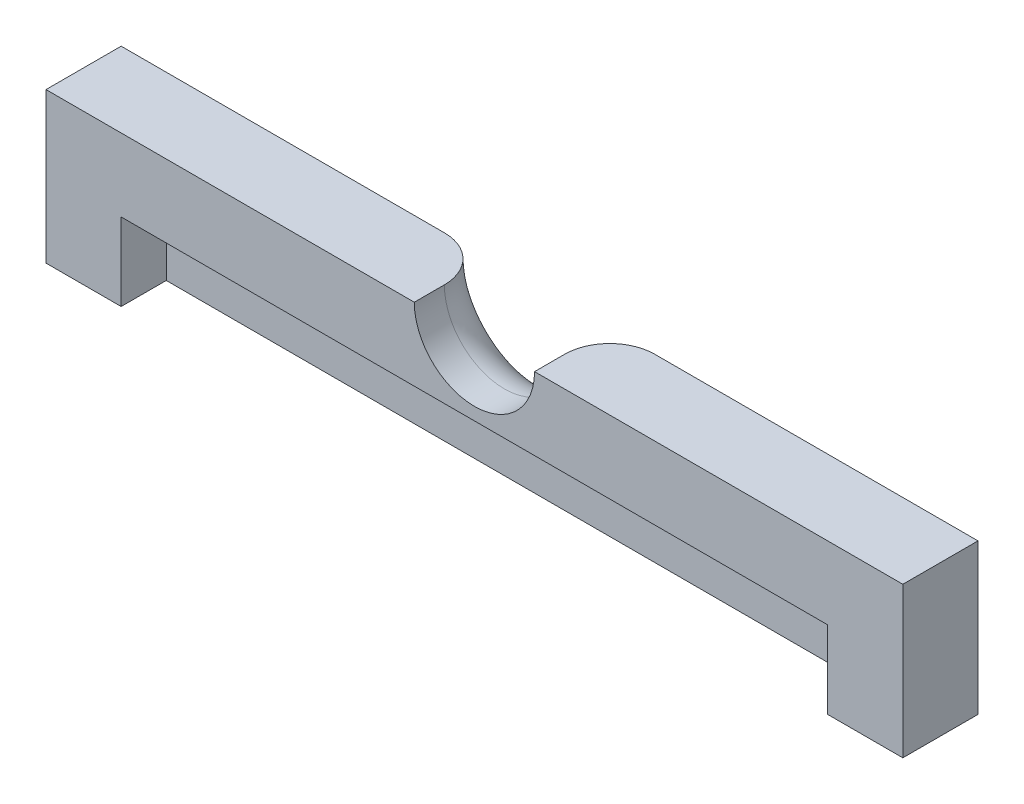
from build123d import *

# Parameters (mm, degrees)
SKETCH1_W           = 57
SKETCH1_H           = 10
BOSS_EXTRUDE1_DEPTH = 5
SKETCH2_W           = 47
SKETCH2_H           = 5.162319645
CUT_EXTRUDE1_DEPTH  = 3
CUT_EXTRUDE2_DEPTH  = 6
FILLET1_R           = 3


with BuildPart() as part:
    # Sketch1 → Boss-Extrude1 (new body)
    with BuildSketch(Plane.XY):
        with Locations((28.5, -5)):
            Rectangle(SKETCH1_W, SKETCH1_H)
    extrude(amount=BOSS_EXTRUDE1_DEPTH)

    # Sketch2 → Cut-Extrude1 (cut)
    with BuildSketch(Plane.XY.offset(5)):
        with Locations((28.5, -7.418840177)):
            Rectangle(SKETCH2_W, SKETCH2_H)
    extrude(amount=-CUT_EXTRUDE1_DEPTH, mode=Mode.SUBTRACT)

    # Sketch3 → Cut-Extrude2 (cut, through all)
    with BuildSketch(Plane(origin=(0, 0, 0), x_dir=(-1, 0, 0), z_dir=(0, 0, -1))):
        with BuildLine():
            Line((-32.5, 0), (-24.5, 0))
            ThreePointArc((-24.5, 0), (-28.5, -4), (-32.5, 0))
        make_face()
    extrude(amount=-CUT_EXTRUDE2_DEPTH, mode=Mode.SUBTRACT)

    # Fillet1
    fillet1_edges = [part.edges().sort_by_distance(p)[0] for p in [
        (28.5, -4, 0),
    ]]
    fillet(fillet1_edges, radius=FILLET1_R)


solid = part.part
